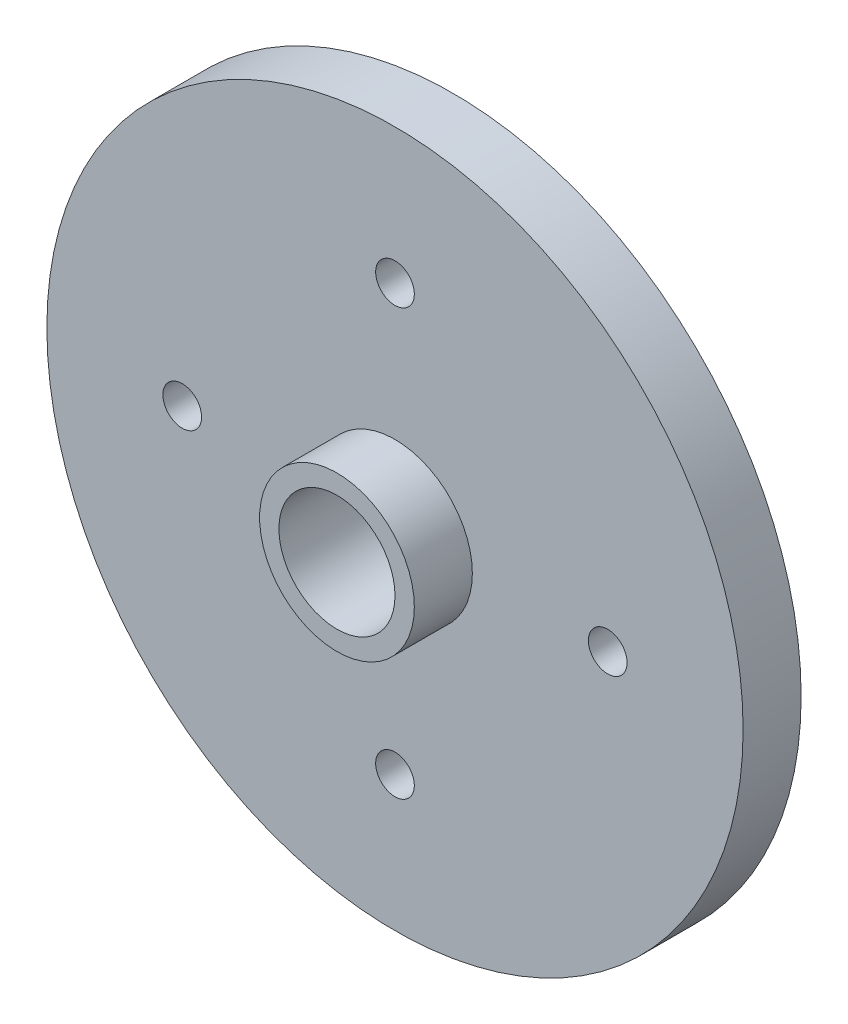
from build123d import *

# Parameters (mm, degrees)
SKETCH1_R           = 18
SKETCH1_R_2         = 1
BOSS_EXTRUDE1_DEPTH = 3
SKETCH2_R           = 4
SKETCH2_R_2         = 3
BOSS_EXTRUDE2_DEPTH = 3
SKETCH3_R           = 3
CUT_EXTRUDE1_DEPTH  = 5


with BuildPart() as part:
    # Sketch1 → Boss-Extrude1 (new body)
    with BuildSketch(Plane.XY):
        Circle(SKETCH1_R)
        with Locations((0, 11)):
            Circle(SKETCH1_R_2, mode=Mode.SUBTRACT)
        with Locations((11, 0)):
            Circle(SKETCH1_R_2, mode=Mode.SUBTRACT)
        with Locations((0, -11)):
            Circle(SKETCH1_R_2, mode=Mode.SUBTRACT)
        with Locations((-11, 0)):
            Circle(SKETCH1_R_2, mode=Mode.SUBTRACT)
    extrude(amount=BOSS_EXTRUDE1_DEPTH)

    # Sketch2 → Boss-Extrude2 (add)
    with BuildSketch(Plane.XY.offset(3)):
        Circle(SKETCH2_R)
        Circle(SKETCH2_R_2, mode=Mode.SUBTRACT)
    extrude(amount=BOSS_EXTRUDE2_DEPTH)

    # Sketch3 → Cut-Extrude1 (cut)
    with BuildSketch(Plane.XY.offset(3)):
        Circle(SKETCH3_R)
    extrude(amount=-CUT_EXTRUDE1_DEPTH, mode=Mode.SUBTRACT)


solid = part.part
